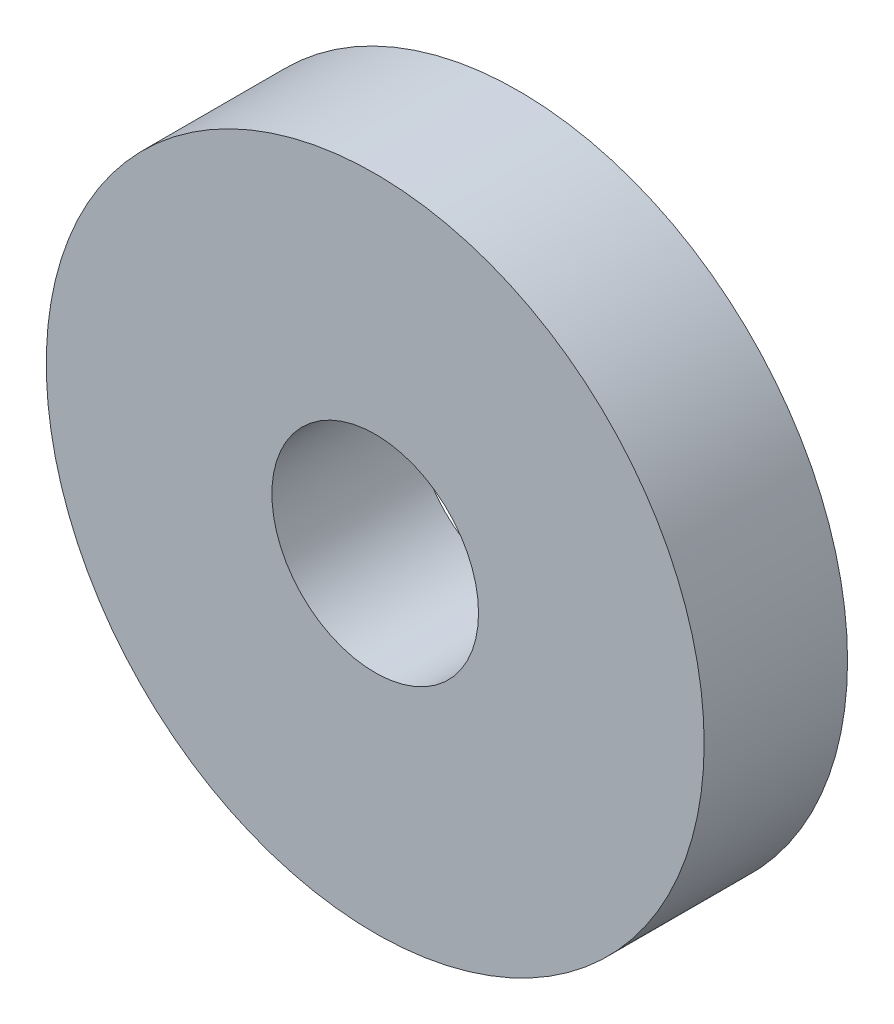
from build123d import *

# Parameters (mm, degrees)
SKETCH1_R      = 3.9624
SKETCH1_R_2    = 1.2446
EXTRUDE1_DEPTH = 1.7272


with BuildPart() as part:
    # Sketch1 → Extrude1 (new body)
    with BuildSketch(Plane.XY):
        Circle(SKETCH1_R)
        Circle(SKETCH1_R_2, mode=Mode.SUBTRACT)
    extrude(amount=-EXTRUDE1_DEPTH)


solid = part.part
